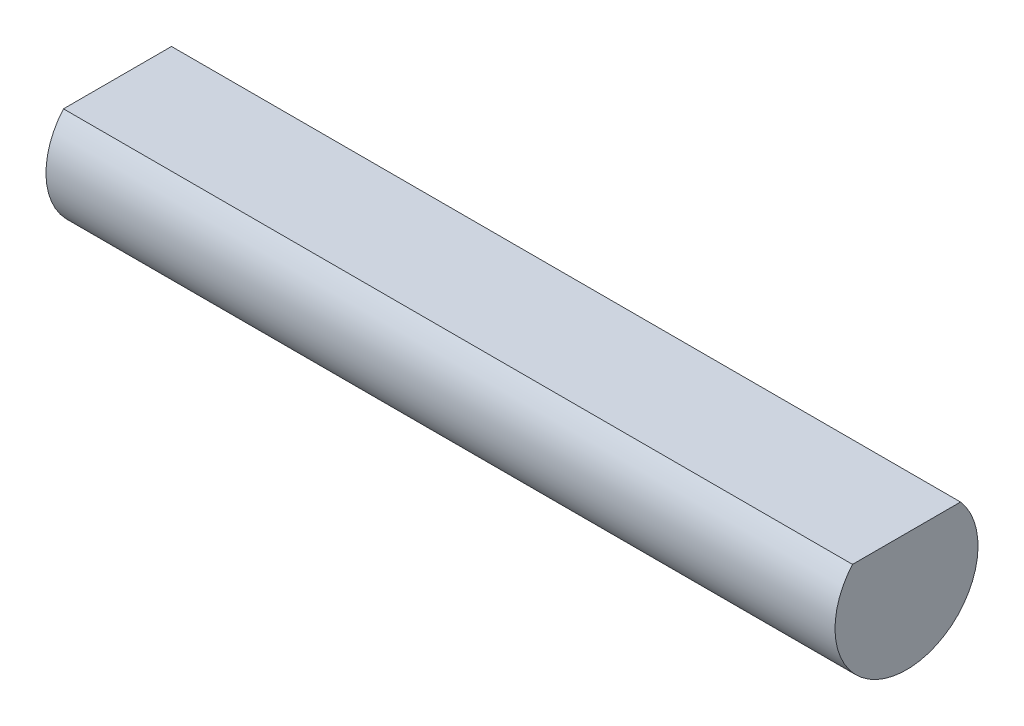
from build123d import *

# Parameters (mm, degrees)
BOSS_EXTRUDE1_DEPTH      = 8
BOSS_EXTRUDE1_DEPTH_BACK = 8


with BuildPart() as part:
    # Sketch1 → Boss-Extrude1 (new, two sides: drawn at the far end of the back side and taken through both)
    with BuildSketch(Plane(origin=(0, 0, 0), x_dir=(0, 0, -1), z_dir=(1, 0, 0)).offset(-BOSS_EXTRUDE1_DEPTH_BACK)):
        with BuildLine():
            ThreePointArc((-1.095445115, 0.95), (0, -1.45), (1.095445115, 0.95))
            Line((1.095445115, 0.95), (-1.095445115, 0.95))
        make_face()
    extrude(amount=BOSS_EXTRUDE1_DEPTH + BOSS_EXTRUDE1_DEPTH_BACK)


solid = part.part
